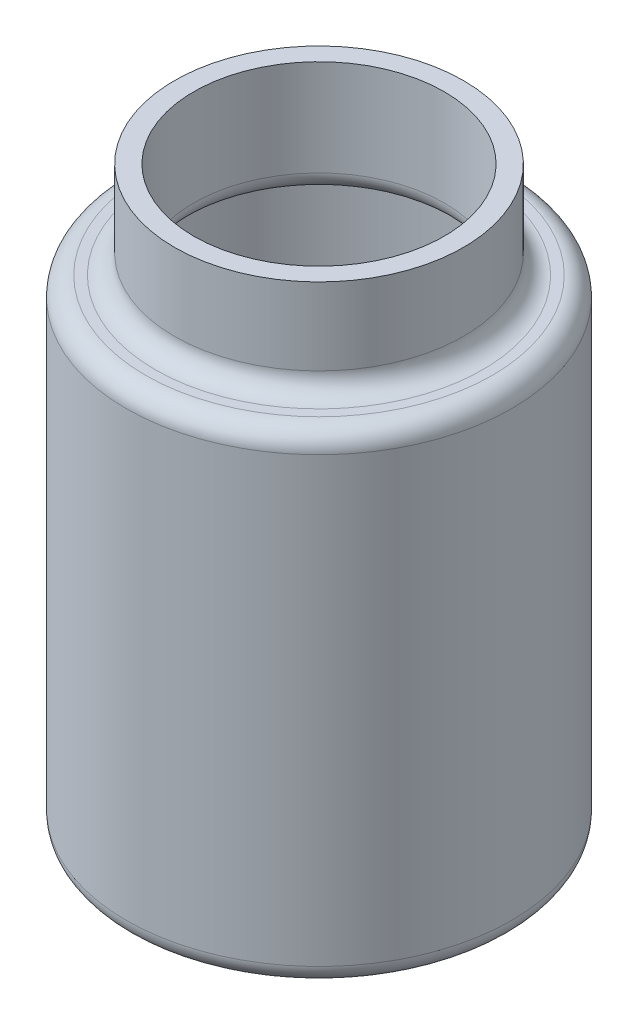
from build123d import *

# Parameters (mm, degrees)
SHELL1_T  = -1
FILLET1_R = 1
FILLET2_R = 1


with BuildPart() as part:
    # Sketch1 → Revolve1 (revolve)
    with BuildSketch(Plane.XY):
        Polygon((0, 0), (0, 30), (-7.5, 30), (-7.5, 25), (-10, 25), (-10, 0), align=None)
    revolve(axis=Axis((0, 30, 0), (0, 1, 0)))

    # Shell1
    shell1_openings = [part.faces().sort_by_distance(p)[0] for p in [
        (0, 30, -7.5),
    ]]
    offset(amount=SHELL1_T, openings=shell1_openings, kind=Kind.INTERSECTION)

    # Fillet1
    fillet1_edges = [part.edges().sort_by_distance(p)[0] for p in [
        (7.5, 25, 0),
        (10, 25, 0),
        (10, 0, 0),
    ]]
    fillet(fillet1_edges, radius=FILLET1_R)

    # Fillet2
    fillet2_edges = [part.edges().sort_by_distance(p)[0] for p in [
        (6.5, 24, 0),
    ]]
    fillet(fillet2_edges, radius=FILLET2_R)


solid = part.part
